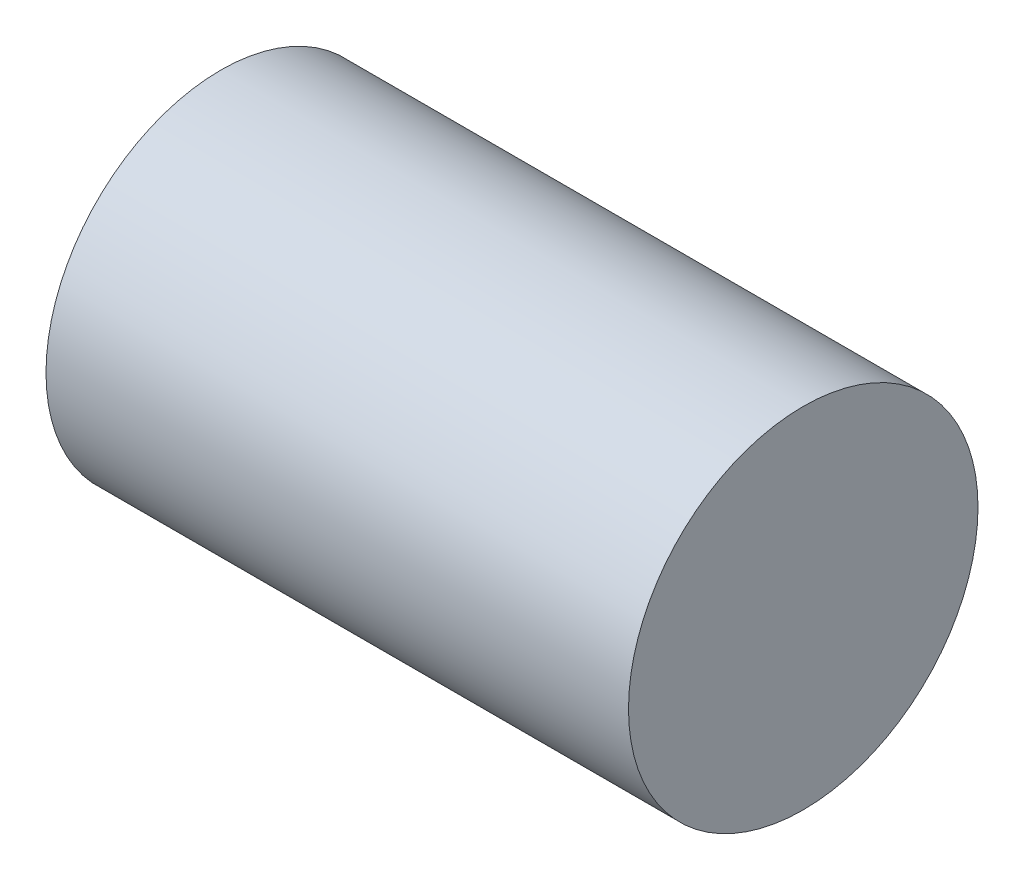
from build123d import *

# Parameters (mm, degrees)
SKETCH1_R           = 3.75
BOSS_EXTRUDE1_DEPTH = 12.5


with BuildPart() as part:
    # Sketch1 → Boss-Extrude1 (new body)
    with BuildSketch(Plane(origin=(0, 0, 0), x_dir=(0, 0, -1), z_dir=(1, 0, 0))):
        Circle(SKETCH1_R)
    extrude(amount=BOSS_EXTRUDE1_DEPTH)


solid = part.part
